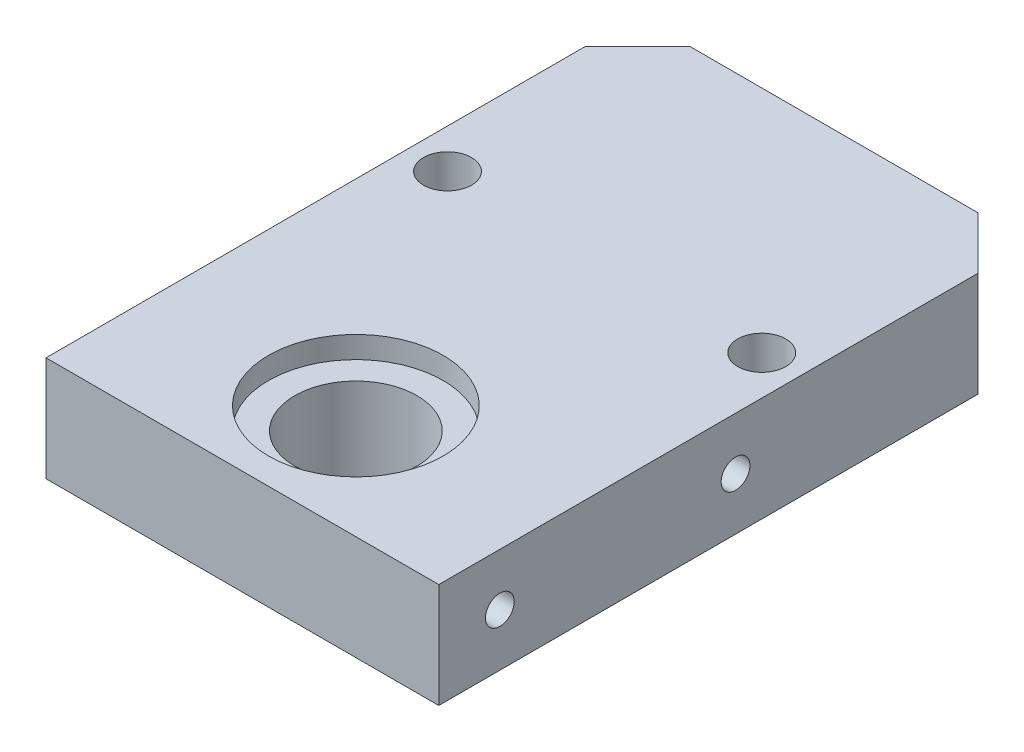
from build123d import *

# Parameters (mm, degrees)
SKETCH1_R             = 2.75
SKETCH1_R_2           = 7
BOSS_EXTRUDE1_DEPTH   = 12
M4_TAPPED_HOLE1_D     = 3.3
M4_TAPPED_HOLE1_DEPTH = 14
M4_TAPPED_HOLE1_TIP   = 0.991420021
M4_TAPPED_HOLE2_D     = 3.3
M4_TAPPED_HOLE2_DEPTH = 14
M4_TAPPED_HOLE2_TIP   = 0.991420021
SKETCH6_R             = 10
CUT_EXTRUDE1_DEPTH    = 2.5


with BuildPart() as part:
    # Sketch1 → Boss-Extrude1 (new body)
    with BuildSketch(Plane(origin=(0, 0, 0), x_dir=(1, 0, 0), z_dir=(0, 1, 0))):
        Polygon((-16.5, 33.888888889), (-22.5, 27.888888889), (-22.5, -33.888888889), (22.5, -33.888888889), (22.5, 27.888888889), (16.5, 33.888888889), align=None)
        with Locations((-18, 7.611111111)):
            Circle(SKETCH1_R, mode=Mode.SUBTRACT)
        with Locations((18, 7.611111111)):
            Circle(SKETCH1_R, mode=Mode.SUBTRACT)
        with Locations((0, -20.888888889)):
            Circle(SKETCH1_R_2, mode=Mode.SUBTRACT)
    extrude(amount=BOSS_EXTRUDE1_DEPTH)

    # M4 Tapped Hole1
    with Locations(Plane.ZY.offset(22.5)):
        with Locations((-0.111111111, 6), (26.888888889, 6)):
            Hole(M4_TAPPED_HOLE1_D / 2, depth=M4_TAPPED_HOLE1_DEPTH)
            with Locations((0, 0, -(M4_TAPPED_HOLE1_DEPTH + M4_TAPPED_HOLE1_TIP / 2))):  # 118° drill point
                Cone(0, M4_TAPPED_HOLE1_D / 2, M4_TAPPED_HOLE1_TIP, mode=Mode.SUBTRACT)

    # M4 Tapped Hole2
    with Locations(Plane(origin=(22.5, 0, 0), x_dir=(0, 0, -1), z_dir=(1, 0, 0))):
        with Locations((-26.888888889, 6), (0.111111111, 6)):
            Hole(M4_TAPPED_HOLE2_D / 2, depth=M4_TAPPED_HOLE2_DEPTH)
            with Locations((0, 0, -(M4_TAPPED_HOLE2_DEPTH + M4_TAPPED_HOLE2_TIP / 2))):  # 118° drill point
                Cone(0, M4_TAPPED_HOLE2_D / 2, M4_TAPPED_HOLE2_TIP, mode=Mode.SUBTRACT)

    # Sketch6 → Cut-Extrude1 (cut)
    with BuildSketch(Plane(origin=(0, 12, 0), x_dir=(1, 0, 0), z_dir=(0, 1, 0))):
        with Locations((0, -20.888888889)):
            Circle(SKETCH6_R)
    extrude(amount=-CUT_EXTRUDE1_DEPTH, mode=Mode.SUBTRACT)


solid = part.part
